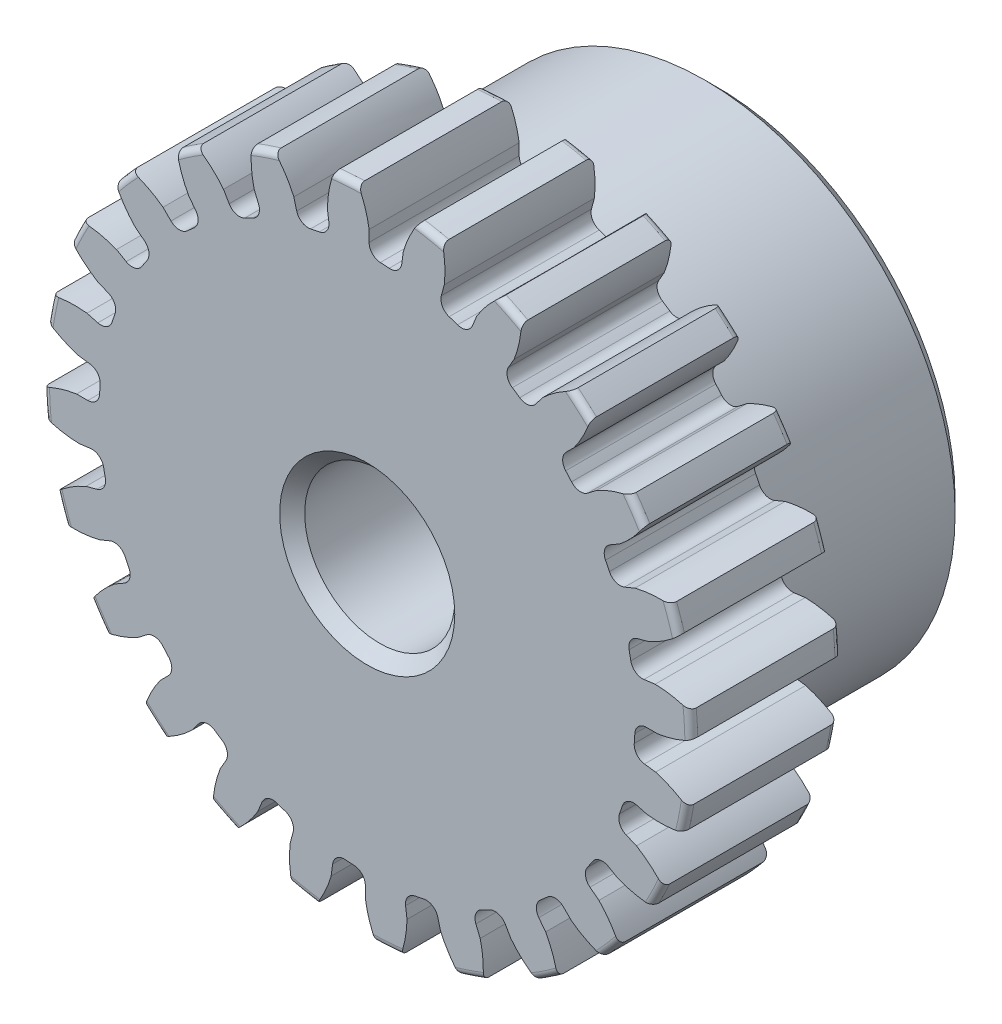
from build123d import *

# Parameters (mm, degrees)
SKETCH1_R                = 10.287
BOSS_EXTRUDE1_DEPTH      = 4.7625
SKETCH2_W                = 6.35
SKETCH2_H                = 7.9375
FILLET2_R                = 0.20574
CUT_EXTRUDE1_DEPTH       = 12.1125
FILLET1_R                = 0.37404675
CIRPATTERN1_COUNT        = 24
FILLET1_OF_CIRPATTERN1_R = 0.37404675
SKETCH5_R                = 2.38125
CUT_EXTRUDE2_DEPTH       = 12.1125
CHAMFER1_SIZE            = 0.396875


with BuildPart() as part:
    # Sketch1 → Boss-Extrude1 (new body)
    with BuildSketch(Plane.XY):
        Circle(SKETCH1_R)
    extrude(amount=-BOSS_EXTRUDE1_DEPTH)

    # Sketch2 → Revolve1 (revolve)
    with BuildSketch(Plane(origin=(0, 0, 0), x_dir=(0, 0, -1), z_dir=(1, 0, 0))):
        with Locations((7.9375, 3.96875)):
            Rectangle(SKETCH2_W, SKETCH2_H)
    revolve(axis=Axis((0, 0, -4.7625), (0, 0, -1)))

    # Fillet2
    fillet2_edges = [part.edges().sort_by_distance(p)[0] for p in [
        (-10.287, 0, 0),
        (-10.287, 0, -4.7625),
        (0, -7.9375, -4.7625),
    ]]
    fillet(fillet2_edges, radius=FILLET2_R)

    # Sketch4 → Cut-Extrude1 (cut, through all)
    with BuildSketch(Plane.XY):
        with BuildLine():
            Line((0.059789782, 9.221412444), (0.059789782, 8.50085224))
            ThreePointArc((0.059789782, 8.50085224), (0.555997388, 8.482860988), (1.050308183, 8.435930082))
            Line((1.050308183, 8.435930082), (1.144360382, 9.150325765))
            add(Edge.make_bspline(
                [(2.406507179, 10.971914406), (1.453557654, 10.222687936), (1.144360382, 9.150325765)],
                knots=[0, 0, 0, 1, 1, 1], degree=2))
            ThreePointArc((2.406507179, 10.971914406), (0.734657289, 11.208677942), (-0.953793542, 11.192160668))
            add(Edge.make_bspline(
                [(-0.953793542, 11.192160668), (-0.106790576, 10.324958803), (0.059789782, 9.221412444)],
                knots=[0, 0, 0, 1, 1, 1], degree=2))
        make_face()
    cut_extrude1 = extrude(amount=-CUT_EXTRUDE1_DEPTH, mode=Mode.SUBTRACT)

    # Fillet1
    fillet1_edges = [part.edges().sort_by_distance(p)[0] for p in [
        (1.050308183, 8.435930082, -2.38125),
        (0.059789782, 8.50085224, -2.38125),
    ]]
    fillet(fillet1_edges, radius=FILLET1_R)

    # CirPattern1: Cut-Extrude1 ×24 about axis
    cirpattern1_axis = Axis((0, 0, -4.7625), (0, 0, 1))
    for i in range(1, CIRPATTERN1_COUNT):
        add(cut_extrude1.rotate(cirpattern1_axis, i * 360 / CIRPATTERN1_COUNT), mode=Mode.SUBTRACT)

    # Fillet1 of CirPattern1
    fillet1_of_cirpattern1_edges = [part.edges().sort_by_distance(p)[0] for p in [
        (-1.168859568, 8.420322496, -2.38125),
        (-2.142429965, 8.226667459, -2.38125),
        (-3.308371472, 7.830883847, -2.38125),
        (-4.19864665, 7.391848885, -2.38125),
        (-5.222423328, 6.707783405, -2.38125),
        (-5.968732505, 6.053288025, -2.38125),
        (-6.780575664, 5.12755861, -2.38125),
        (-7.332059103, 4.30220559, -2.38125),
        (-7.876642974, 3.197899168, -2.38125),
        (-8.19571799, 2.257934954, -2.38125),
        (-8.435930082, 1.050308183, -2.38125),
        (-8.50085224, 0.059789782, -2.38125),
        (-8.420322496, -1.168859568, -2.38125),
        (-8.226667459, -2.142429965, -2.38125),
        (-7.830883847, -3.308371472, -2.38125),
        (-7.391848885, -4.19864665, -2.38125),
        (-6.707783405, -5.222423328, -2.38125),
        (-6.053288025, -5.968732505, -2.38125),
        (-5.12755861, -6.780575664, -2.38125),
        (-4.30220559, -7.332059103, -2.38125),
        (-3.197899168, -7.876642974, -2.38125),
        (-2.257934954, -8.19571799, -2.38125),
        (-1.050308183, -8.435930082, -2.38125),
        (-0.059789782, -8.50085224, -2.38125),
        (1.168859568, -8.420322496, -2.38125),
        (2.142429965, -8.226667459, -2.38125),
        (3.308371472, -7.830883847, -2.38125),
        (4.19864665, -7.391848885, -2.38125),
        (5.222423328, -6.707783405, -2.38125),
        (5.968732505, -6.053288025, -2.38125),
        (6.780575664, -5.12755861, -2.38125),
        (7.332059103, -4.30220559, -2.38125),
        (7.876642974, -3.197899168, -2.38125),
        (8.19571799, -2.257934954, -2.38125),
        (8.435930082, -1.050308183, -2.38125),
        (8.50085224, -0.059789782, -2.38125),
        (8.420322496, 1.168859568, -2.38125),
        (8.226667459, 2.142429965, -2.38125),
        (7.830883847, 3.308371472, -2.38125),
        (7.391848885, 4.19864665, -2.38125),
        (6.707783405, 5.222423328, -2.38125),
        (6.053288025, 5.968732505, -2.38125),
        (5.12755861, 6.780575664, -2.38125),
        (4.30220559, 7.332059103, -2.38125),
        (3.197899168, 7.876642974, -2.38125),
        (2.257934954, 8.19571799, -2.38125),
    ]]
    fillet(fillet1_of_cirpattern1_edges, radius=FILLET1_OF_CIRPATTERN1_R)

    # Sketch5 → Cut-Extrude2 (cut, through all)
    with BuildSketch(Plane.XY):
        Circle(SKETCH5_R)
    extrude(amount=-CUT_EXTRUDE2_DEPTH, mode=Mode.SUBTRACT)

    # Chamfer1
    chamfer1_edges = [part.edges().sort_by_distance(p)[0] for p in [
        (-2.38125, 0, -11.1125),
        (-2.38125, 0, 0),
        (0, -7.9375, -11.1125),
    ]]
    chamfer(chamfer1_edges, length=CHAMFER1_SIZE)


solid = part.part
